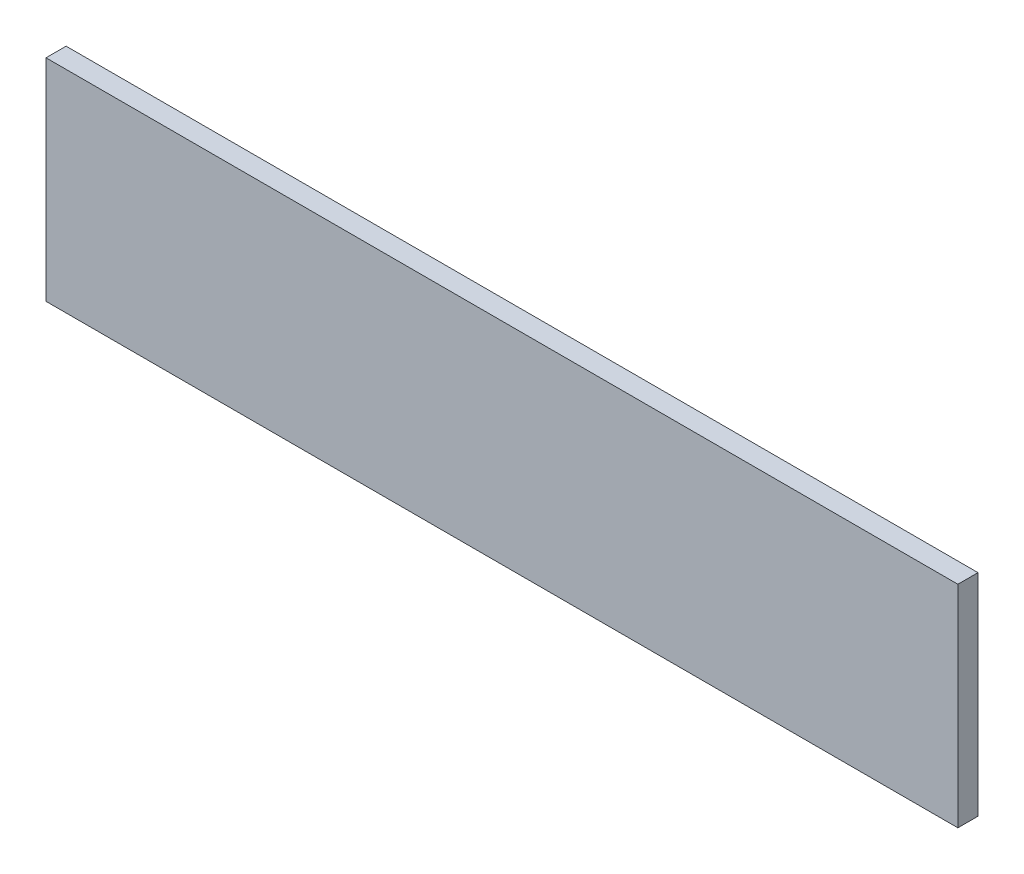
from build123d import *

# Parameters (mm, degrees)
SKETCH1_W           = 3.06
SKETCH1_H           = 32.08
BOSS_EXTRUDE1_DEPTH = 138.67


with BuildPart() as part:
    # Sketch1 → Boss-Extrude1 (new body)
    with BuildSketch(Plane(origin=(0, 0, 0), x_dir=(0, 0, -1), z_dir=(1, 0, 0))):
        with Locations((1.53, 16.04)):
            Rectangle(SKETCH1_W, SKETCH1_H)
    extrude(amount=BOSS_EXTRUDE1_DEPTH)


solid = part.part
